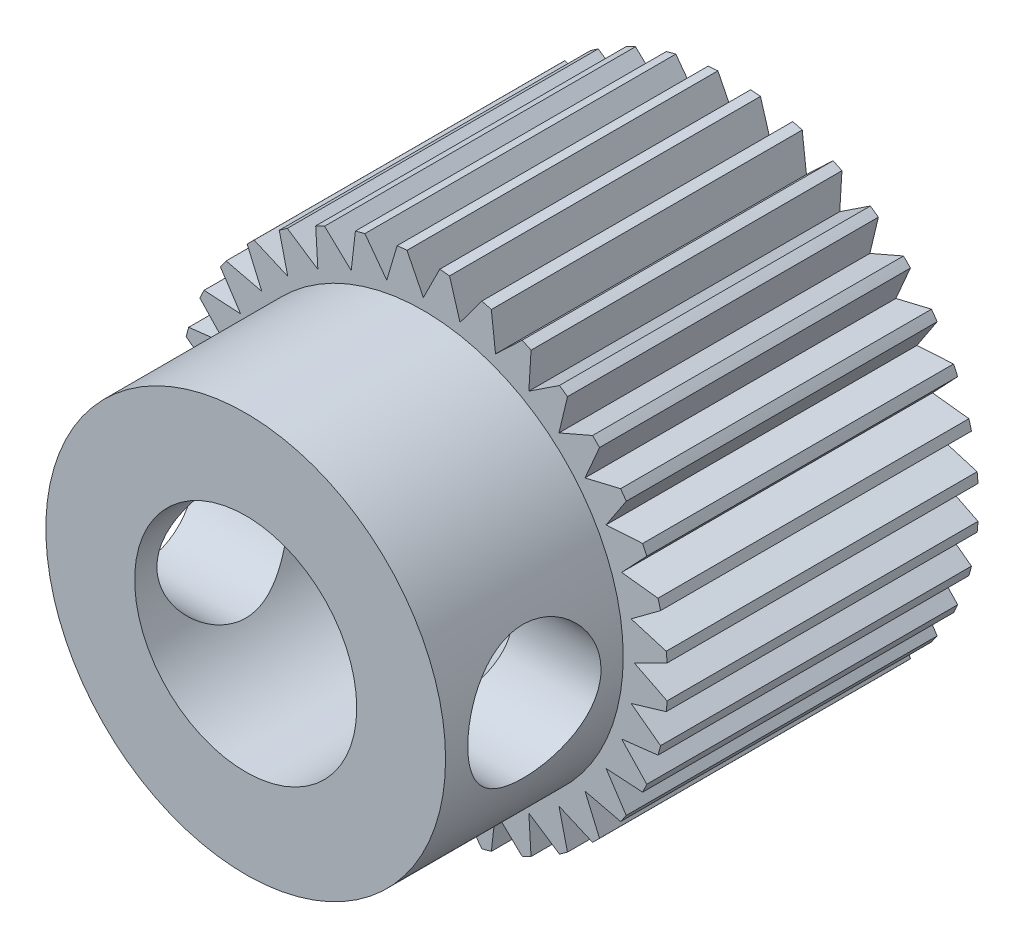
from build123d import *

# Parameters (mm, degrees)
SKETCH1_R               = 5.5
BOSS_EXTRUDE1_DEPTH     = 7
CUT_EXTRUDE3_DEPTH      = 7
SKETCH3_R               = 4.5
BOSS_EXTRUDE2_DEPTH     = 4
SKETCH4_R               = 1.5
CUT_EXTRUDE4_DEPTH      = 6
CUT_EXTRUDE4_DEPTH_BACK = 6
SKETCH5_R               = 2.5
CUT_EXTRUDE5_DEPTH      = 12


with BuildPart() as part:
    # Sketch1 → Boss-Extrude1 (new body)
    with BuildSketch(Plane.XY):
        Circle(SKETCH1_R)
    extrude(amount=BOSS_EXTRUDE1_DEPTH)

    # Sketch2 → Cut-Extrude3 (cut)
    with BuildSketch(Plane.XY.offset(7)):
        Polygon((0, 4.75), (-0.5, 5.75), (0.5, 5.75), align=None)
        Polygon((0.824828844, 4.677836827), (0.506073145, 5.749468669), (1.490880898, 5.575820491), align=None)
        Polygon((1.624595681, 4.463539949), (1.496769514, 5.574242641), (2.436462135, 5.232222498), align=None)
        Polygon((2.375, 4.113620668), (2.441987298, 5.229646072), (3.308012702, 4.729646072), align=None)
        Polygon((3.053241146, 3.638711105), (3.313006534, 4.726149353), (4.079050977, 4.083361743), align=None)
        Polygon((3.638711105, 3.053241146), (4.083361743, 4.079050977), (4.726149353, 3.313006534), align=None)
        Polygon((4.113620668, 2.375), (4.729646072, 3.308012702), (5.229646072, 2.441987298), align=None)
        Polygon((4.463539949, 1.624595681), (5.232222498, 2.436462135), (5.574242641, 1.496769514), align=None)
        Polygon((4.677836827, 0.824828844), (5.575820491, 1.490880898), (5.749468669, 0.506073145), align=None)
        Polygon((4.75, 0), (5.75, 0.5), (5.75, -0.5), align=None)
        Polygon((4.677836827, -0.824828844), (5.749468669, -0.506073145), (5.575820491, -1.490880898), align=None)
        Polygon((4.463539949, -1.624595681), (5.574242641, -1.496769514), (5.232222498, -2.436462135), align=None)
        Polygon((4.113620668, -2.375), (5.229646072, -2.441987298), (4.729646072, -3.308012702), align=None)
        Polygon((3.638711105, -3.053241146), (4.726149353, -3.313006534), (4.083361743, -4.079050977), align=None)
        Polygon((3.053241146, -3.638711105), (4.079050977, -4.083361743), (3.313006534, -4.726149353), align=None)
        Polygon((2.375, -4.113620668), (3.308012702, -4.729646072), (2.441987298, -5.229646072), align=None)
        Polygon((1.624595681, -4.463539949), (2.436462135, -5.232222498), (1.496769514, -5.574242641), align=None)
        Polygon((0.824828844, -4.677836827), (1.490880898, -5.575820491), (0.506073145, -5.749468669), align=None)
        Polygon((0, -4.75), (0.5, -5.75), (-0.5, -5.75), align=None)
        Polygon((-0.824828844, -4.677836827), (-0.506073145, -5.749468669), (-1.490880898, -5.575820491), align=None)
        Polygon((-1.624595681, -4.463539949), (-1.496769514, -5.574242641), (-2.436462135, -5.232222498), align=None)
        Polygon((-2.375, -4.113620668), (-2.441987298, -5.229646072), (-3.308012702, -4.729646072), align=None)
        Polygon((-3.053241146, -3.638711105), (-3.313006534, -4.726149353), (-4.079050977, -4.083361743), align=None)
        Polygon((-3.638711105, -3.053241146), (-4.083361743, -4.079050977), (-4.726149353, -3.313006534), align=None)
        Polygon((-4.113620668, -2.375), (-4.729646072, -3.308012702), (-5.229646072, -2.441987298), align=None)
        Polygon((-4.463539949, -1.624595681), (-5.232222498, -2.436462135), (-5.574242641, -1.496769514), align=None)
        Polygon((-4.677836827, -0.824828844), (-5.575820491, -1.490880898), (-5.749468669, -0.506073145), align=None)
        Polygon((-4.75, 0), (-5.75, -0.5), (-5.75, 0.5), align=None)
        Polygon((-4.677836827, 0.824828844), (-5.749468669, 0.506073145), (-5.575820491, 1.490880898), align=None)
        Polygon((-4.463539949, 1.624595681), (-5.574242641, 1.496769514), (-5.232222498, 2.436462135), align=None)
        Polygon((-4.113620668, 2.375), (-5.229646072, 2.441987298), (-4.729646072, 3.308012702), align=None)
        Polygon((-3.638711105, 3.053241146), (-4.726149353, 3.313006534), (-4.083361743, 4.079050977), align=None)
        Polygon((-3.053241146, 3.638711105), (-4.079050977, 4.083361743), (-3.313006534, 4.726149353), align=None)
        Polygon((-2.375, 4.113620668), (-3.308012702, 4.729646072), (-2.441987298, 5.229646072), align=None)
        Polygon((-1.624595681, 4.463539949), (-2.436462135, 5.232222498), (-1.496769514, 5.574242641), align=None)
        Polygon((-0.824828844, 4.677836827), (-1.490880898, 5.575820491), (-0.506073145, 5.749468669), align=None)
    extrude(amount=-CUT_EXTRUDE3_DEPTH, mode=Mode.SUBTRACT)

    # Sketch3 → Boss-Extrude2 (add)
    with BuildSketch(Plane.XY.offset(7)):
        Circle(SKETCH3_R)
    extrude(amount=BOSS_EXTRUDE2_DEPTH)

    # Sketch4 → Cut-Extrude4 (cut, two sides)
    with BuildSketch(Plane(origin=(0, 0, 0), x_dir=(0, 0, -1), z_dir=(1, 0, 0))) as cut_extrude4_sk:
        with Locations((-9, 0)):
            Circle(SKETCH4_R)
    extrude(amount=CUT_EXTRUDE4_DEPTH, mode=Mode.SUBTRACT)
    extrude(cut_extrude4_sk.sketch, amount=-CUT_EXTRUDE4_DEPTH_BACK, mode=Mode.SUBTRACT)

    # Sketch5 → Cut-Extrude5 (cut)
    with BuildSketch(Plane.XY.offset(11)):
        Circle(SKETCH5_R)
    extrude(amount=-CUT_EXTRUDE5_DEPTH, mode=Mode.SUBTRACT)


solid = part.part
